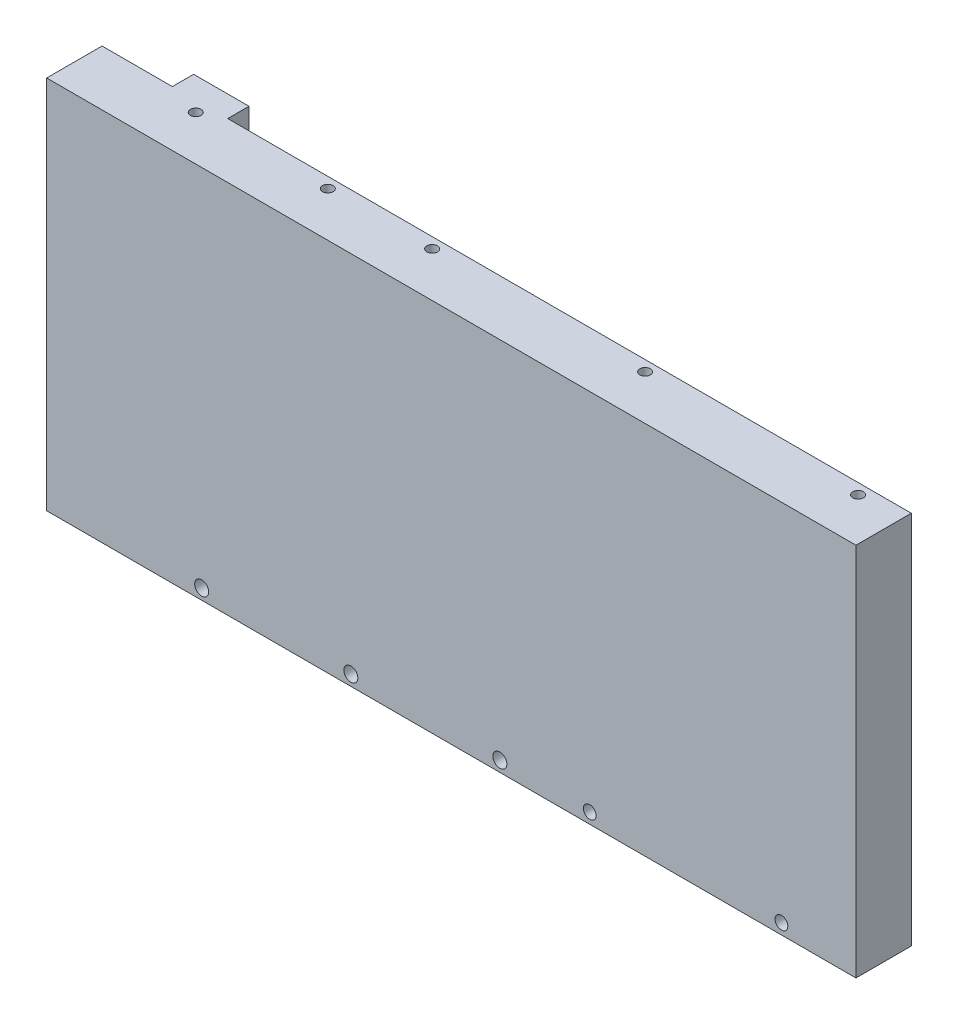
from build123d import *

# Parameters (mm, degrees)
BOSS_EXTRUDE1_DEPTH    = 13
SKETCH3_R              = 1.65
SKETCH3_R_2            = 1.5
CUT_EXTRUDE1_DEPTH     = 14
SKETCH4_W              = 13
SKETCH4_H              = 83
BOSS_EXTRUDE2_DEPTH    = 5
BOSS_EXTRUDE3_DEPTH    = 1
FILLET1_R              = 2
HOLE_WIZARD_M3_1_D     = 2.5
HOLE_WIZARD_M3_1_DEPTH = 12
HOLE_WIZARD_M3_1_TIP   = 0.751075774
CUT_EXTRUDE_1_DEPTH    = 17


with BuildPart() as part:
    # Sketch1 → Boss-Extrude1 (new body)
    with BuildSketch(Plane.XY):
        Polygon((-95, 44), (-35, 44), (95, 44), (95, -44), (-95, -44), align=None)
    extrude(amount=BOSS_EXTRUDE1_DEPTH)

    # Sketch3 → Cut-Extrude1 (cut, through all)
    with BuildSketch(Plane.XY.offset(13)):
        with Locations((-58.6, -41.5)):
            Circle(SKETCH3_R)
        with Locations((-23.6, -41.5)):
            Circle(SKETCH3_R)
        with Locations((11.4, -41.5)):
            Circle(SKETCH3_R)
        with Locations((32.5, -41.5)):
            Circle(SKETCH3_R_2)
        with Locations((77.5, -41.5)):
            Circle(SKETCH3_R_2)
    extrude(amount=-CUT_EXTRUDE1_DEPTH, mode=Mode.SUBTRACT)

    # Sketch4 → Boss-Extrude2 (add)
    with BuildSketch(Plane(origin=(0, 0, 0), x_dir=(-1, 0, 0), z_dir=(0, 0, -1))):
        with Locations((72, 2.5)):
            Rectangle(SKETCH4_W, SKETCH4_H)
    extrude(amount=BOSS_EXTRUDE2_DEPTH)

    # Sketch5 → Boss-Extrude3 (add)
    with BuildSketch(Plane(origin=(0, 0, 0), x_dir=(-1, 0, 0), z_dir=(0, 0, -1))):
        Polygon((65.5, -39), (-15, -39), (-15, -34), (-14, -34), (-14, -38), (65.5, -38), align=None)
    extrude(amount=BOSS_EXTRUDE3_DEPTH)

    # Fillet1
    fillet1_edges = [part.edges().sort_by_distance(p)[0] for p in [
        (14, -38, -0.5),
    ]]
    fillet(fillet1_edges, radius=FILLET1_R)

    # M3 螺纹孔1
    with Locations(Plane(origin=(-70.5, 44, 2.5), x_dir=(1, 0, 0), z_dir=(0, 1, 0))):
        with Locations((0, 0), (31, 0), (55.5, 0), (105.5, 0), (155.5, 0)):
            Hole(HOLE_WIZARD_M3_1_D / 2, depth=HOLE_WIZARD_M3_1_DEPTH)
            with Locations((0, 0, -(HOLE_WIZARD_M3_1_DEPTH + HOLE_WIZARD_M3_1_TIP / 2))):  # 118° drill point
                Cone(0, HOLE_WIZARD_M3_1_D / 2, HOLE_WIZARD_M3_1_TIP, mode=Mode.SUBTRACT)

    # 草图4 → 切除-拉伸1 (cut)
    with BuildSketch(Plane(origin=(0, 0, -5), x_dir=(-1, 0, 0), z_dir=(0, 0, -1))):
        with BuildLine():
            Line((29.5, 29), (29.5, 4))
            ThreePointArc((29.5, 4), (36.5, -3), (43.5, 4))
            Line((43.5, 4), (43.5, 29))
            ThreePointArc((43.5, 29), (36.5, 36), (29.5, 29))
        make_face()
    extrude(amount=-CUT_EXTRUDE_1_DEPTH, mode=Mode.SUBTRACT)


solid = part.part
